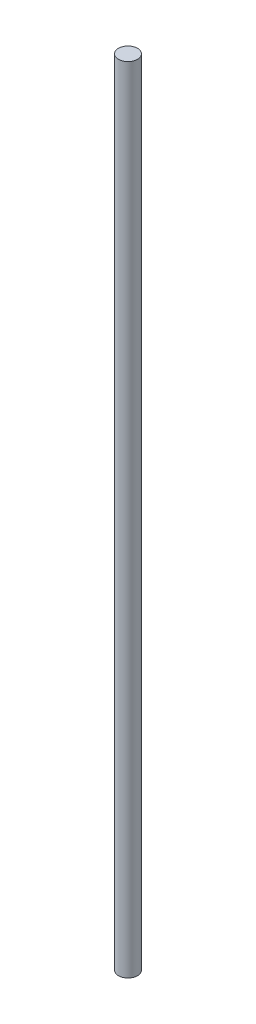
from build123d import *

# Parameters (mm, degrees)
SKETCH1_R           = 4
BOSS_EXTRUDE1_DEPTH = 332.5


with BuildPart() as part:
    # Sketch1 → Boss-Extrude1 (new body)
    with BuildSketch(Plane(origin=(0, 0, 0), x_dir=(1, 0, 0), z_dir=(0, 1, 0))):
        Circle(SKETCH1_R)
    extrude(amount=BOSS_EXTRUDE1_DEPTH)


solid = part.part
